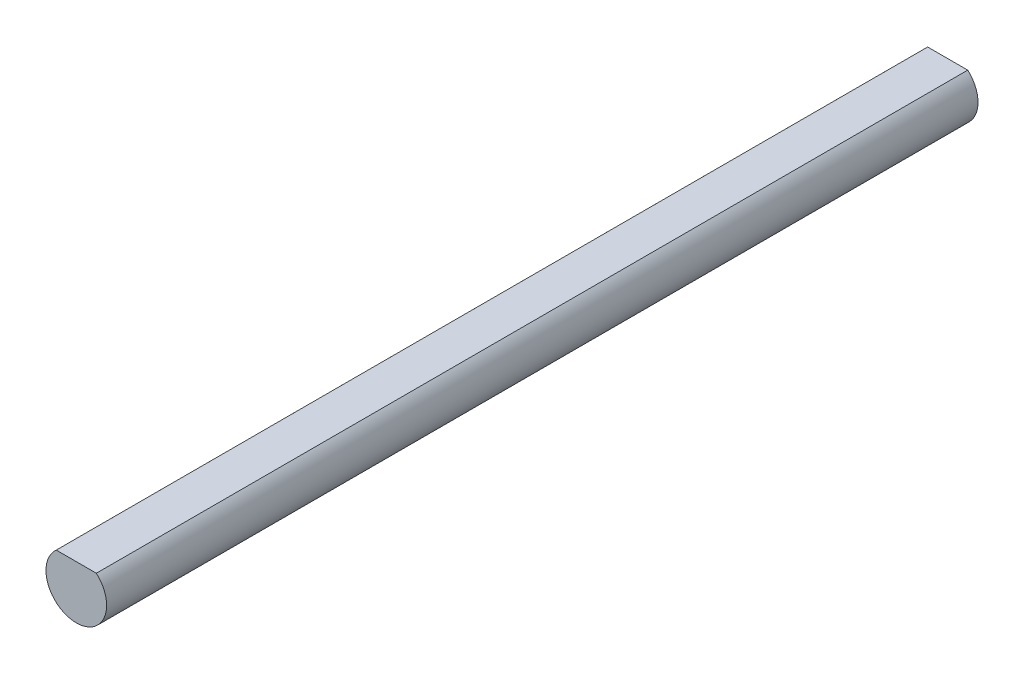
from build123d import *

# Parameters (mm, degrees)
SKETCH1_R           = 4
BOSS_EXTRUDE1_DEPTH = 115
CUT_EXTRUDE1_REACH  = 117


with BuildPart() as part:
    # Sketch1 → Boss-Extrude1 (new body)
    with BuildSketch(Plane.XY):
        Circle(SKETCH1_R)
    extrude(amount=BOSS_EXTRUDE1_DEPTH)

    # Sketch2 → Cut-Extrude1 (cut, up to next)
    with BuildSketch(Plane.XY.offset(115), mode=Mode.PRIVATE) as cut_extrude1_sk1:
        with BuildLine():
            Line((-2.645751311, 3), (2.645751311, 3))
            ThreePointArc((2.645751311, 3), (0, 4), (-2.645751311, 3))
        make_face()
    cut_extrude1_tool1 = extrude(cut_extrude1_sk1.sketch, amount=-CUT_EXTRUDE1_REACH, mode=Mode.PRIVATE) & part.part
    add(cut_extrude1_tool1.solids().sort_by_distance((0, 3.404621, 115))[0], mode=Mode.SUBTRACT)


solid = part.part
